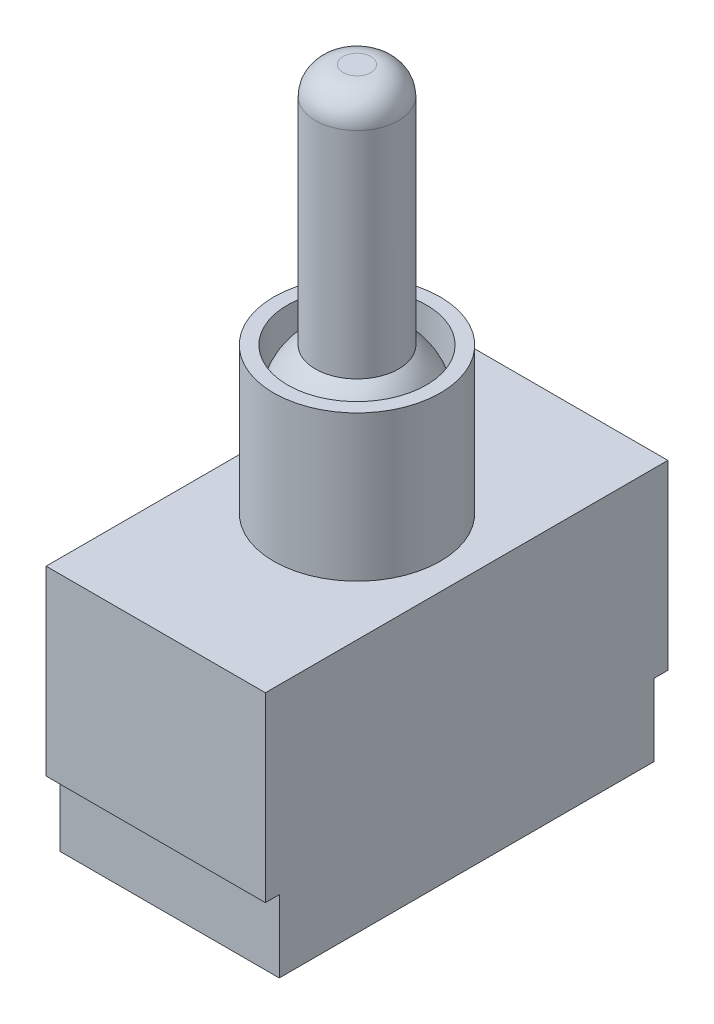
from build123d import *

# Parameters (mm, degrees)
SKETCH1_W           = 15.8
SKETCH1_H           = 29
BOSS_EXTRUDE1_DEPTH = 13.1
SKETCH2_R           = 6
BOSS_EXTRUDE2_DEPTH = 10.5
SKETCH4_R           = 5
CUT_EXTRUDE1_DEPTH  = 4
SKETCH5_R           = 3
BOSS_EXTRUDE3_DEPTH = 21.5
REVOLVE2_ANGLE      = 180
FILLET1_R           = 2
SKETCH6_W           = 15.8
SKETCH6_H           = 27
BOSS_EXTRUDE4_DEPTH = 5.2


with BuildPart() as part:
    # Sketch1 → Boss-Extrude1 (new body)
    with BuildSketch(Plane(origin=(0, 0, 0), x_dir=(1, 0, 0), z_dir=(0, 1, 0))):
        Rectangle(SKETCH1_W, SKETCH1_H)
    extrude(amount=BOSS_EXTRUDE1_DEPTH)

    # Sketch2 → Boss-Extrude2 (add)
    with BuildSketch(Plane(origin=(0, 13.1, 0), x_dir=(1, 0, 0), z_dir=(0, 1, 0))):
        Circle(SKETCH2_R)
    extrude(amount=BOSS_EXTRUDE2_DEPTH)

    # Sketch4 → Cut-Extrude1 (cut)
    with BuildSketch(Plane(origin=(0, 23.6, 0), x_dir=(1, 0, 0), z_dir=(0, 1, 0))):
        Circle(SKETCH4_R)
    extrude(amount=-CUT_EXTRUDE1_DEPTH, mode=Mode.SUBTRACT)

    # Sketch5 → Boss-Extrude3 (add)
    with BuildSketch(Plane(origin=(0, 19.6, 0), x_dir=(1, 0, 0), z_dir=(0, 1, 0))):
        Circle(SKETCH5_R)
    extrude(amount=BOSS_EXTRUDE3_DEPTH)

    # Sketch3 → Revolve2 (revolve)
    with BuildSketch(Plane(origin=(0, 19.6, 0), x_dir=(1, 0, 0), z_dir=(0, 1, 0))):
        with BuildLine():
            Line((0, -5), (0, 5))
            ThreePointArc((0, 5), (-5, 0), (0, -5))
        make_face()
    revolve(axis=Axis((0, 19.6, 6), (0, 0, -1)), revolution_arc=REVOLVE2_ANGLE)

    # Fillet1
    fillet1_edges = [part.edges().sort_by_distance(p)[0] for p in [
        (-3, 41.1, 0),
    ]]
    fillet(fillet1_edges, radius=FILLET1_R)

    # Sketch6 → Boss-Extrude4 (add)
    with BuildSketch(Plane.XZ):
        Rectangle(SKETCH6_W, SKETCH6_H)
    extrude(amount=BOSS_EXTRUDE4_DEPTH)


solid = part.part
